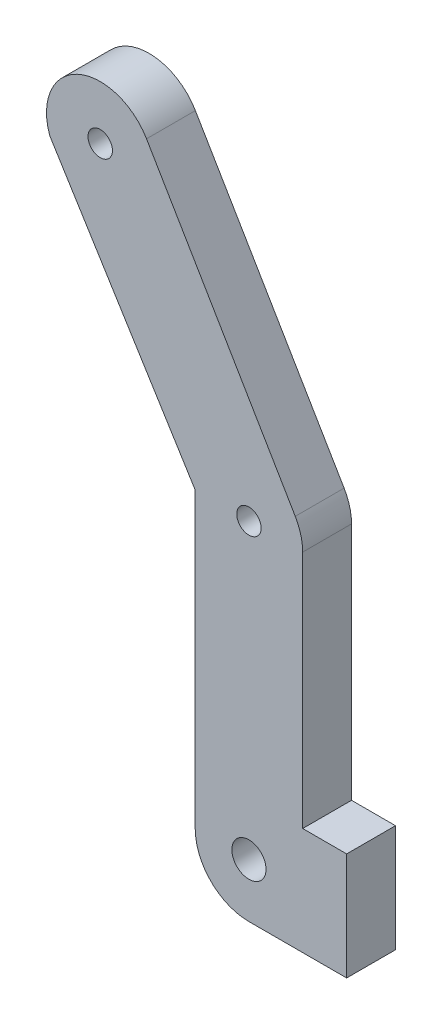
from build123d import *

# Parameters (mm, degrees)
SKETCH1_R           = 1.75
SKETCH1_R_2         = 1.25
BOSS_EXTRUDE1_DEPTH = 5


with BuildPart() as part:
    # Sketch1 → Boss-Extrude1 (new body)
    with BuildSketch(Plane.XY):
        with BuildLine():
            Line((274.735652315, 354.190888595), (274.735652315, 378.690888595))
            ThreePointArc((274.735652315, 378.690888595), (274.542108821, 380.137097205), (273.975099827, 381.481522444))
            Line((273.975099827, 381.481522444), (258.753460649, 407.333054329))
            ThreePointArc((258.753460649, 407.333054329), (251.662864877, 409.514553006), (248.849842147, 402.649978145))
            Line((248.849842147, 402.649978145), (250.029730466, 400.750917928))
            Line((250.029730466, 400.750917928), (263.735652315, 378.690888595))
            Line((263.735652315, 378.690888595), (263.735652315, 348.690888595))
            ThreePointArc((263.735652315, 348.690888595), (265.346565018, 344.801801299), (269.235652315, 343.190888595))
            Line((269.235652315, 343.190888595), (279.235652315, 343.190888595))
            Line((279.235652315, 343.190888595), (279.235652315, 354.190888595))
            Line((279.235652315, 354.190888595), (274.735652315, 354.190888595))
        make_face()
        with Locations((269.235652315, 348.690888595)):
            Circle(SKETCH1_R, mode=Mode.SUBTRACT)
        with Locations((254.014013137, 404.542420479)):
            Circle(SKETCH1_R_2, mode=Mode.SUBTRACT)
        with Locations((269.235652315, 378.690888595)):
            Circle(SKETCH1_R_2, mode=Mode.SUBTRACT)
    extrude(amount=BOSS_EXTRUDE1_DEPTH)


solid = part.part
